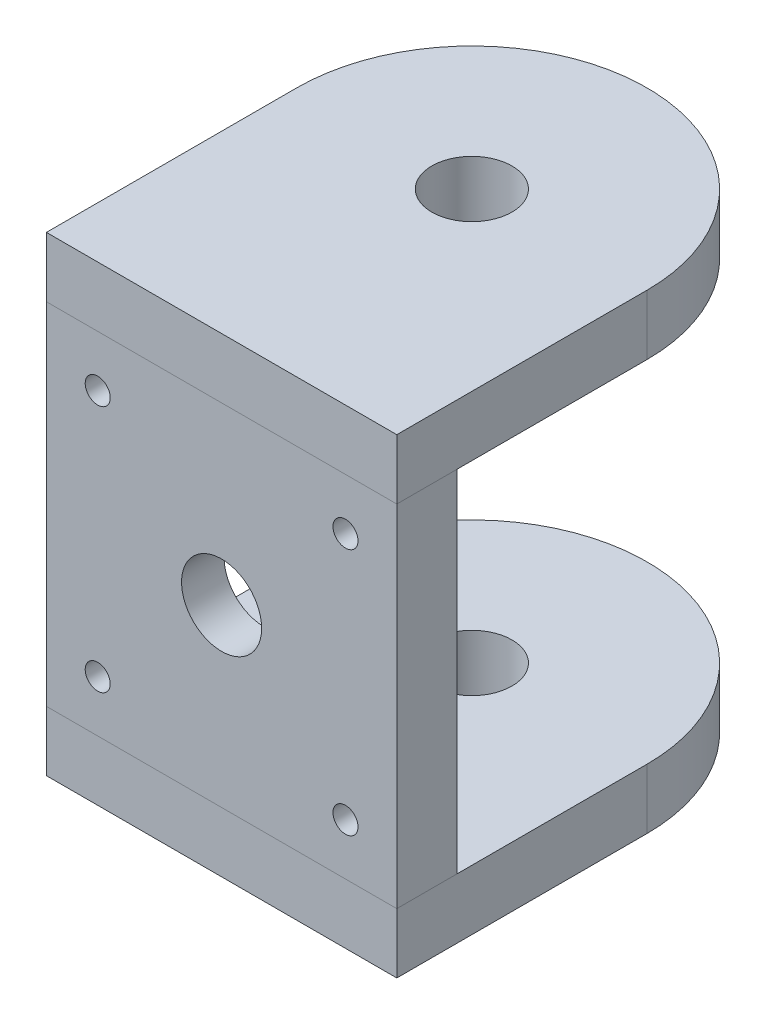
from build123d import *

# Parameters (mm, degrees)
SKETCH1_W               = 70
SKETCH1_H               = 70
SKETCH1_R               = 2.5
SKETCH1_R_2             = 8
BOSS_EXTRUDE2_DEPTH     = 12
SKETCH1_5_R             = 25
CUT_EXTRUDE2_DEPTH      = 3.5
SKETCH2_R               = 2.75
CUT_EXTRUDE3_DEPTH      = 8
SKETCH3_W               = 70
SKETCH3_H               = 100
BOSS_EXTRUDE3_DEPTH     = 12
CUT_EXTRUDE4_DEPTH      = 134.435377618
CUT_EXTRUDE4_DEPTH_BACK = 134.435377618
SKETCH5_R               = 8
CUT_EXTRUDE5_DEPTH      = 134.435377618
CUT_EXTRUDE5_DEPTH_BACK = 134.435377618


with BuildPart() as part:
    # Sketch1 → Boss-Extrude2 (new body)
    with BuildSketch(Plane(origin=(0, 0, 0), x_dir=(0, 1, 0), z_dir=(0, 0, 1))):
        Rectangle(SKETCH1_W, SKETCH1_H)
        with Locations((-24.748737342, -24.748737342)):
            Circle(SKETCH1_R, mode=Mode.SUBTRACT)
        with Locations((24.748737342, -24.748737342)):
            Circle(SKETCH1_R, mode=Mode.SUBTRACT)
        with Locations((-24.748737342, 24.748737342)):
            Circle(SKETCH1_R, mode=Mode.SUBTRACT)
        with Locations((24.748737342, 24.748737342)):
            Circle(SKETCH1_R, mode=Mode.SUBTRACT)
        Circle(SKETCH1_R_2, mode=Mode.SUBTRACT)
    extrude(amount=BOSS_EXTRUDE2_DEPTH)

    # Sketch1_5 → Cut-Extrude2 (cut)
    with BuildSketch(Plane(origin=(0, 0, 0), x_dir=(0, 1, 0), z_dir=(0, 0, 1))):
        Circle(SKETCH1_5_R)
    extrude(amount=CUT_EXTRUDE2_DEPTH, mode=Mode.SUBTRACT)

    # Sketch2 → Cut-Extrude3 (cut)
    with BuildSketch(Plane(origin=(0, 35, 0), x_dir=(-1, 0, 0), z_dir=(0, 1, 0))):
        with Locations((0, 6)):
            Circle(SKETCH2_R)
        with Locations((18, 6)):
            Circle(SKETCH2_R)
        with Locations((-18, 6)):
            Circle(SKETCH2_R)
    cut_extrude3 = extrude(amount=-CUT_EXTRUDE3_DEPTH, mode=Mode.SUBTRACT)

    # Mirror2: Cut-Extrude3 across plane
    add(cut_extrude3.mirror(Plane.ZX), mode=Mode.SUBTRACT)


with BuildPart() as body_2:
    # Sketch3 → Boss-Extrude3 (new body)
    with BuildSketch(Plane(origin=(0, 35, 0), x_dir=(-1, 0, 0), z_dir=(0, 1, 0))):
        with Locations((0, -38)):
            Rectangle(SKETCH3_W, SKETCH3_H)
    extrude(amount=BOSS_EXTRUDE3_DEPTH)


with BuildPart() as body_3:
    # Mirror1: mirrored copy
    add(body_2.part.mirror(Plane.ZX))


with BuildPart() as cut_extrude4_tool:
    # Sketch5 → Cut-Extrude4 (new, two sides: drawn at the far end of the back side and taken through both)
    with BuildSketch(Plane(origin=(0, 47, 0), x_dir=(-1, 0, 0), z_dir=(0, 1, 0)).offset(-CUT_EXTRUDE4_DEPTH_BACK)):
        with Locations((0, -38)):
            Circle(SKETCH5_R)
    extrude(amount=CUT_EXTRUDE4_DEPTH + CUT_EXTRUDE4_DEPTH_BACK)


with BuildPart() as body_2_1:
    add(body_2.part)

    # Cut-Extrude4: cut by cut_extrude4_tool
    add(cut_extrude4_tool.part, mode=Mode.SUBTRACT)


with BuildPart() as body_3_1:
    add(body_3.part)

    # Cut-Extrude4: cut by cut_extrude4_tool
    add(cut_extrude4_tool.part, mode=Mode.SUBTRACT)


with BuildPart() as cut_extrude5_tool:
    # Sketch6 → Cut-Extrude5 (new, two sides: drawn at the far end of the back side and taken through both)
    with BuildSketch(Plane(origin=(0, 47, 0), x_dir=(-1, 0, 0), z_dir=(0, 1, 0)).offset(-CUT_EXTRUDE5_DEPTH_BACK)):
        with BuildLine():
            Line((-35, -38), (-35, -88))
            Line((-35, -88), (35, -88))
            Line((35, -88), (35, -38))
            ThreePointArc((35, -38), (0, -73), (-35, -38))
        make_face()
    extrude(amount=CUT_EXTRUDE5_DEPTH + CUT_EXTRUDE5_DEPTH_BACK)


with BuildPart() as body_2_2:
    add(body_2_1.part)

    # Cut-Extrude5: cut by cut_extrude5_tool
    add(cut_extrude5_tool.part, mode=Mode.SUBTRACT)


with BuildPart() as body_3_2:
    add(body_3_1.part)

    # Cut-Extrude5: cut by cut_extrude5_tool
    add(cut_extrude5_tool.part, mode=Mode.SUBTRACT)


solid = Compound([part.part, body_2_2.part, body_3_2.part])
